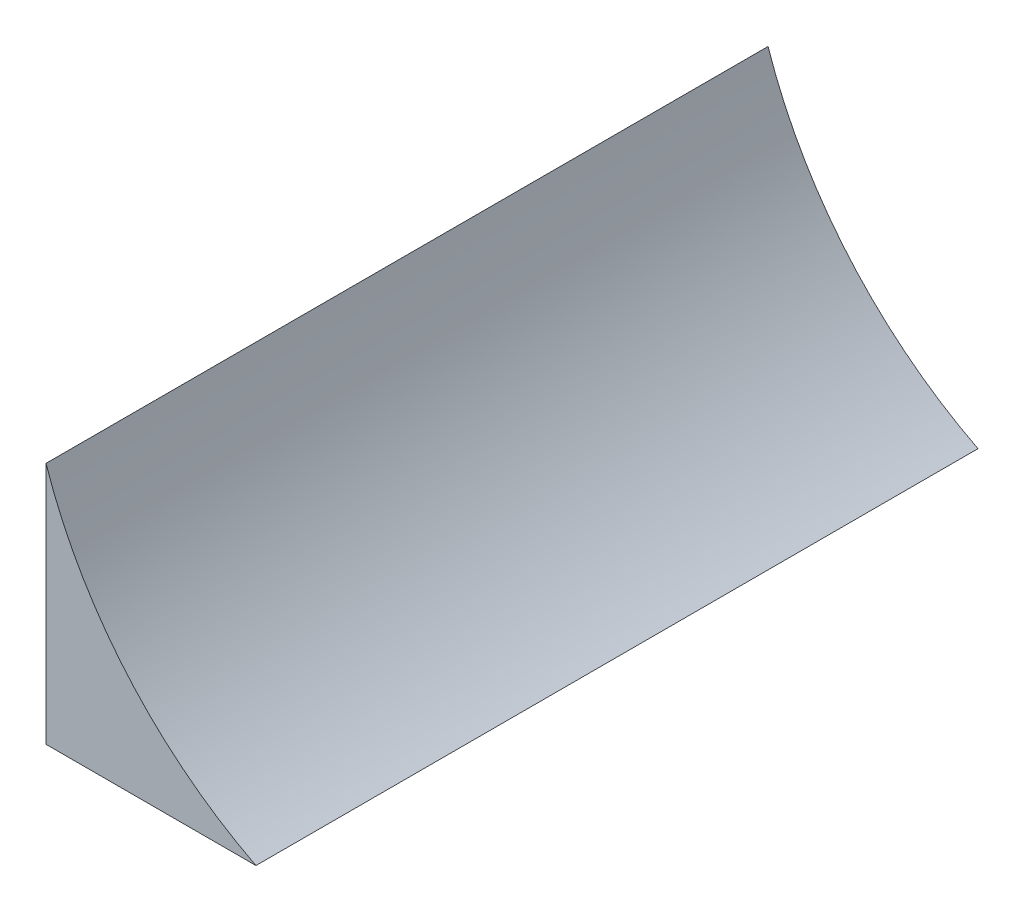
from build123d import *

# Parameters (mm, degrees)
BOSS_EXTRUDE1_DEPTH = 254


with BuildPart() as part:
    # Sketch1 → Boss-Extrude1 (new body)
    with BuildSketch(Plane.XY):
        with BuildLine():
            Line((0, 0), (0, 85.606275272))
            ThreePointArc((0, 85.606275272), (28.541370829, 35.567444317), (73.856394352, 0))
            Line((73.856394352, 0), (0, 0))
        make_face()
    extrude(amount=BOSS_EXTRUDE1_DEPTH)


solid = part.part
